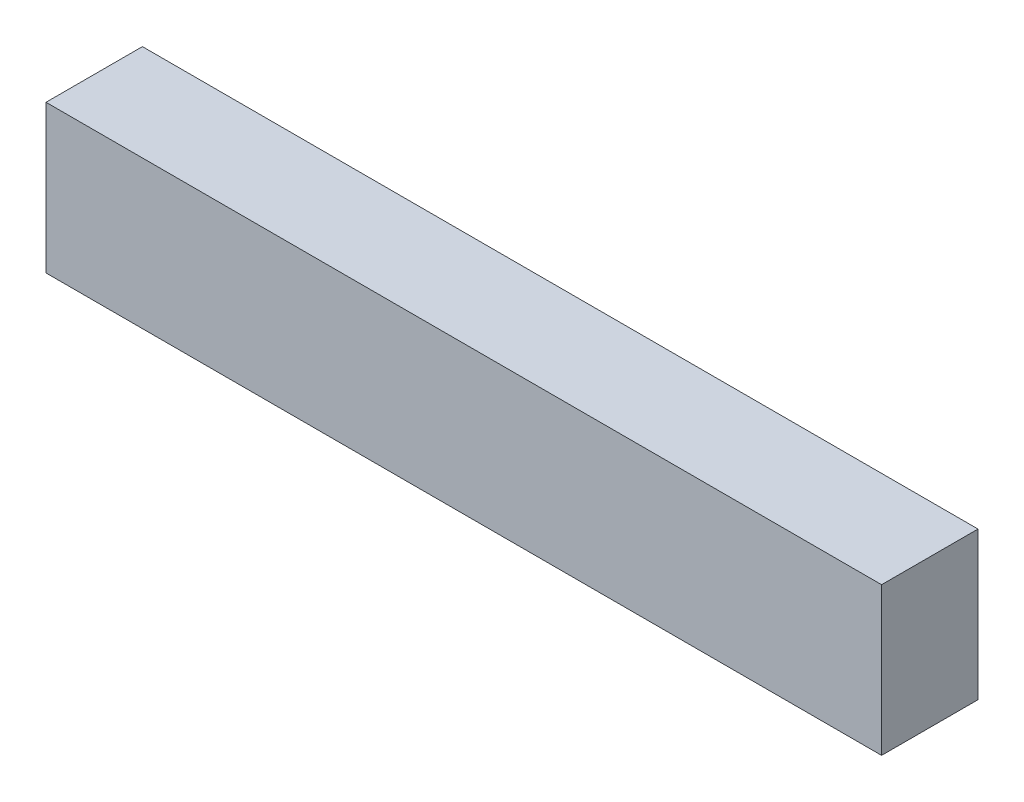
from build123d import *

# Parameters (mm, degrees)
SKETCH2_W           = 130
SKETCH2_H           = 15
BOSS_EXTRUDE1_DEPTH = 23


with BuildPart() as part:
    # Sketch2 → Boss-Extrude1 (new body)
    with BuildSketch(Plane(origin=(0, 0, 0), x_dir=(1, 0, 0), z_dir=(0, 1, 0))):
        Rectangle(SKETCH2_W, SKETCH2_H)
    extrude(amount=BOSS_EXTRUDE1_DEPTH)


solid = part.part
